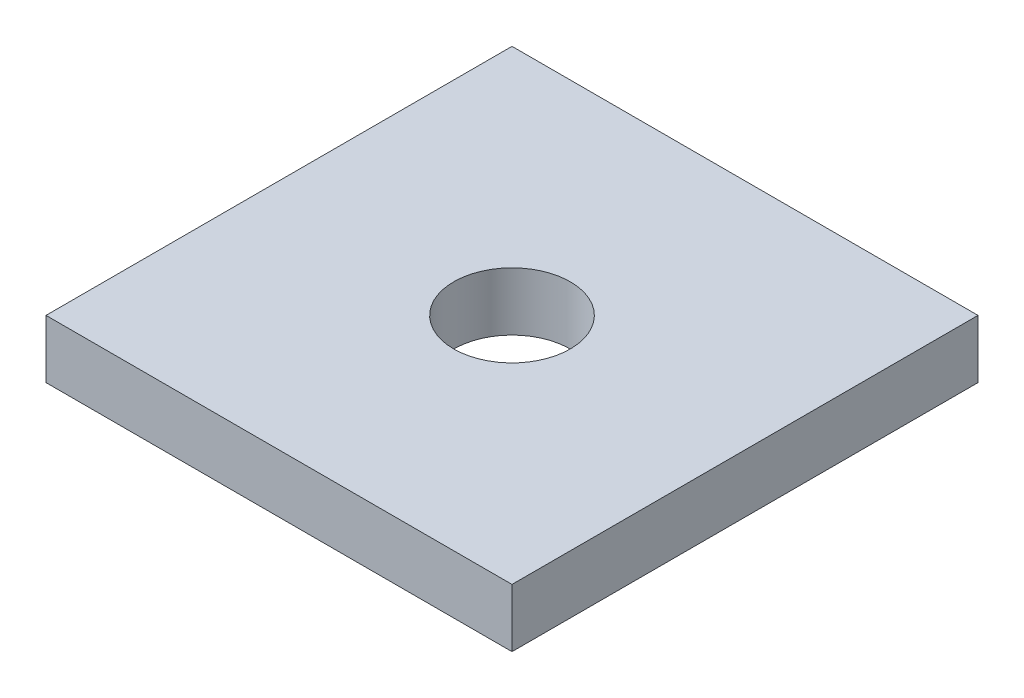
from build123d import *

# Parameters (mm, degrees)
SKETCH1_W           = 76.2
SKETCH1_H           = 76.2
SKETCH1_R           = 9.525
BOSS_EXTRUDE1_DEPTH = 9.525


with BuildPart() as part:
    # Sketch1 → Boss-Extrude1 (new body)
    with BuildSketch(Plane(origin=(0, 0, 0), x_dir=(1, 0, 0), z_dir=(0, 1, 0))):
        with Locations((38.1, 38.1)):
            Rectangle(SKETCH1_W, SKETCH1_H)
        with Locations((38.1, 38.1)):
            Circle(SKETCH1_R, mode=Mode.SUBTRACT)
    extrude(amount=BOSS_EXTRUDE1_DEPTH)


solid = part.part
